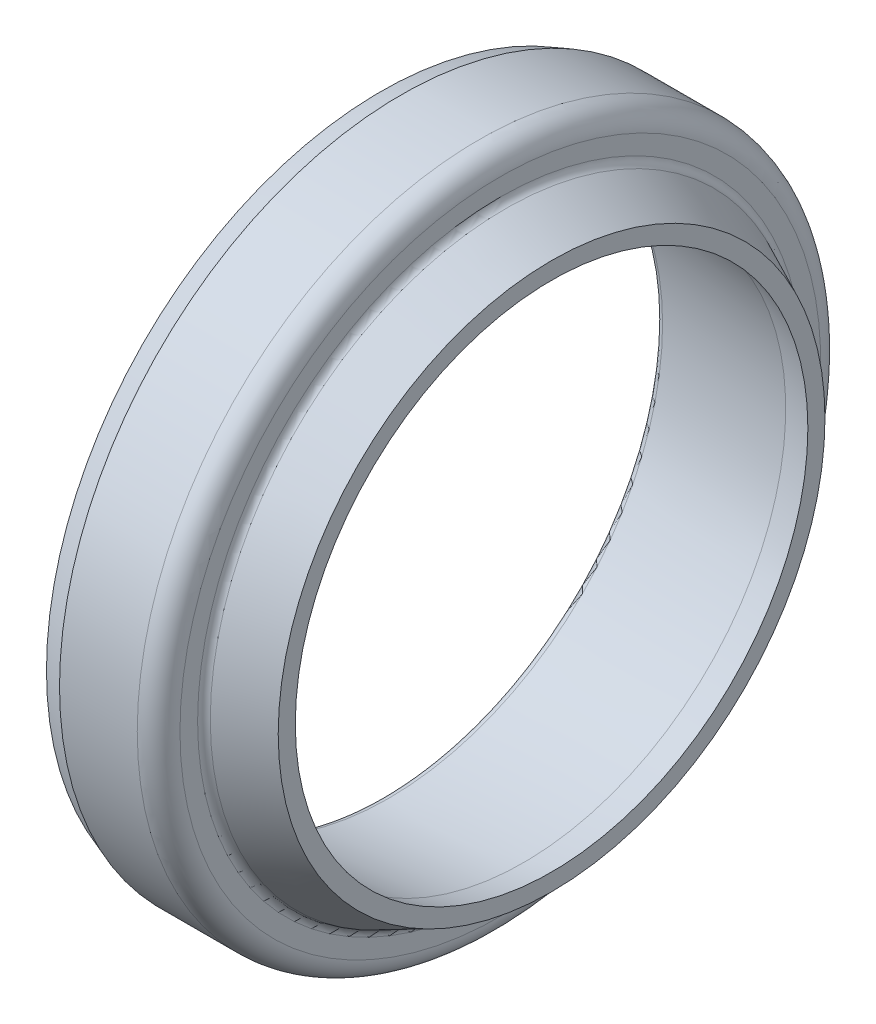
from build123d import *


with BuildPart() as part:
    # Sketch1 → Revolve1 (revolve)
    with BuildSketch(Plane.XY):
        with BuildLine():
            Line((577.061665053, 423.226990018), (577.061665053, 420.51598161))
            add(Edge.make_bspline(
                [(577.061665053, 420.51598161), (577.061665053, 420.242966746), (577.246111222, 420.041679075), (577.518087182, 420.017884261)],
                knots=[0, 0, 0, 0, 1, 1, 1, 1], degree=3, weights=[1, 0.824851558, 0.824851558, 1]))
            Line((577.518087182, 420.017884261), (585.415044515, 419.326990018))
            Line((585.415044515, 419.326990018), (587.061665053, 418.976990018))
            Line((587.061665053, 418.976990018), (587.061665053, 419.976990018))
            Line((587.061665053, 419.976990018), (584.350355922, 421.24129423))
            add(Edge.make_bspline(
                [(584.061665053, 421.694448123), (584.061665053, 421.494469327), (584.169113582, 421.325808921), (584.350355922, 421.24129423)],
                knots=[0, 0, 0, 0, 1, 1, 1, 1], degree=3, weights=[1, 0.895594297, 0.895594297, 1]))
            Line((584.061665053, 421.694448123), (584.061665053, 422.726990018))
            add(Edge.make_bspline(
                [(584.061665053, 422.726990018), (584.061665053, 423.459223065), (583.5438981, 423.976990018), (582.811665053, 423.976990018)],
                knots=[0, 0, 0, 0, 1, 1, 1, 1], degree=3, weights=[1, 0.804737854, 0.804737854, 1]))
            Line((582.811665053, 423.976990018), (578.261665053, 423.976990018))
            Line((578.261665053, 423.976990018), (577.061665053, 423.540225737))
            Line((577.061665053, 423.540225737), (577.061665053, 423.226990018))
        make_face()
    revolve(axis=Axis((577.061665053, 403.976990018, 0), (1, 0, 0)))


solid = part.part
